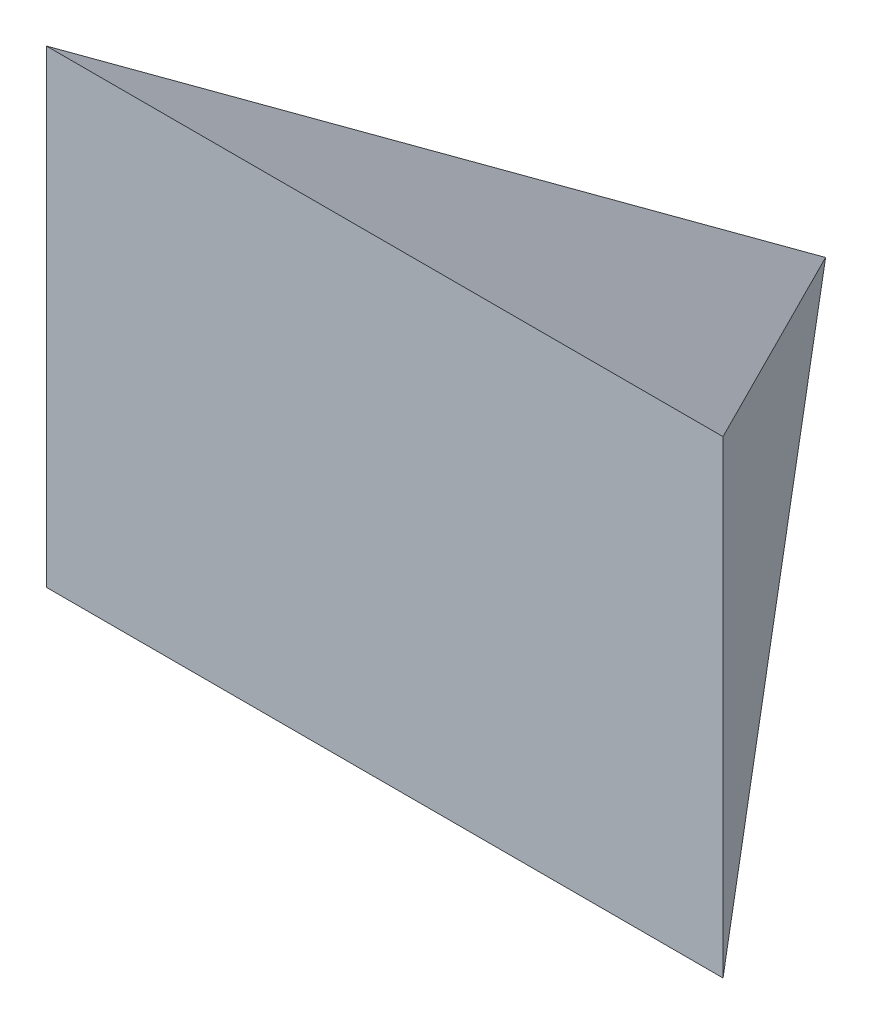
from build123d import *

# Parameters (mm, degrees)
BOSS_EXTRUDE1_DEPTH     = 250
SKETCH2_OUTSIDE_W       = 290.704
SKETCH2_OUTSIDE_H       = 340.704
CUT_EXTRUDE1_DEPTH      = 154.465397596
CUT_EXTRUDE1_DEPTH_BACK = 154.465397596


with BuildPart() as part:
    # Sketch1 → Boss-Extrude1 (new body)
    with BuildSketch(Plane(origin=(0, 0, 0), x_dir=(1, 0, 0), z_dir=(0, 1, 0))):
        Polygon((0, 0), (-153.465397596, -200), (153.465397596, -200), align=None)
    extrude(amount=BOSS_EXTRUDE1_DEPTH)

    # Sketch2 outside → Cut-Extrude1 (cut, two sides)
    with BuildSketch(Plane(origin=(0, 0, 0), x_dir=(0, 0, -1), z_dir=(1, 0, 0))) as cut_extrude1_sk:
        with Locations((-100, 125)):
            Rectangle(SKETCH2_OUTSIDE_W, SKETCH2_OUTSIDE_H)
        Polygon((0, 125), (-200, 231.341886332), (-200, 18.658113668), align=None, mode=Mode.SUBTRACT)
    extrude(amount=CUT_EXTRUDE1_DEPTH, mode=Mode.SUBTRACT)
    extrude(cut_extrude1_sk.sketch, amount=-CUT_EXTRUDE1_DEPTH_BACK, mode=Mode.SUBTRACT)


solid = part.part
